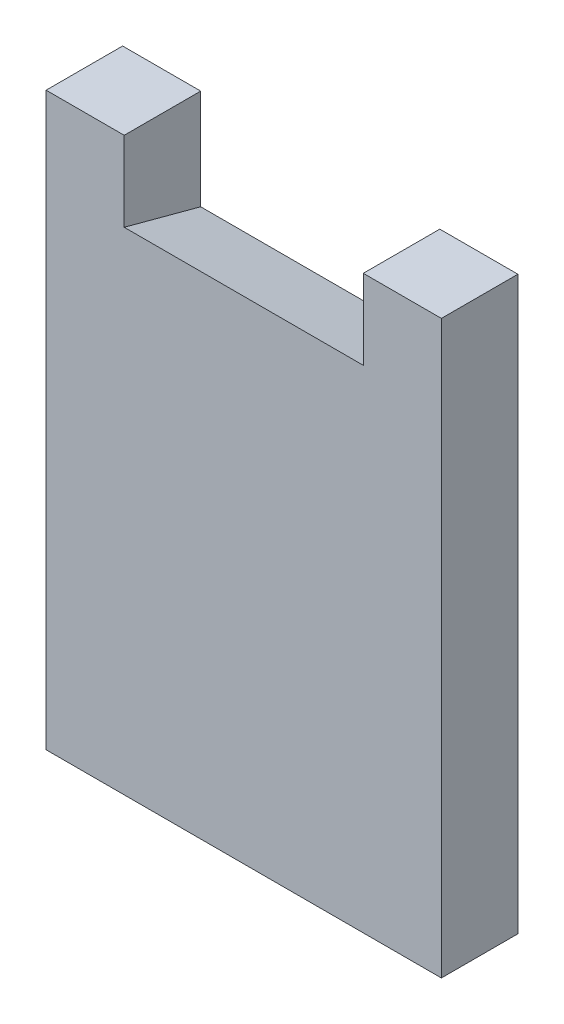
from build123d import *

# Parameters (mm, degrees)
EXTRUDE_1_DEPTH = 9.6
DRAFT_5_ANGLE   = -15


with BuildPart() as part:
    # 草图1 → 凸台-拉伸1 (new body)
    with BuildSketch(Plane.XY):
        Polygon((9.8, 0), (0, 0), (0, -71.68), (49.6, -71.68), (49.6, 0), (39.8, 0), (39.8, -10), (9.8, -10), align=None)
    extrude(amount=EXTRUDE_1_DEPTH)

    # 拔模5
    draft_5_faces = [part.faces().sort_by_distance(p)[0] for p in [
        (24.8, -10, 4.8),
    ]]
    draft(draft_5_faces, Plane.XY.offset(9.6), DRAFT_5_ANGLE)


solid = part.part
